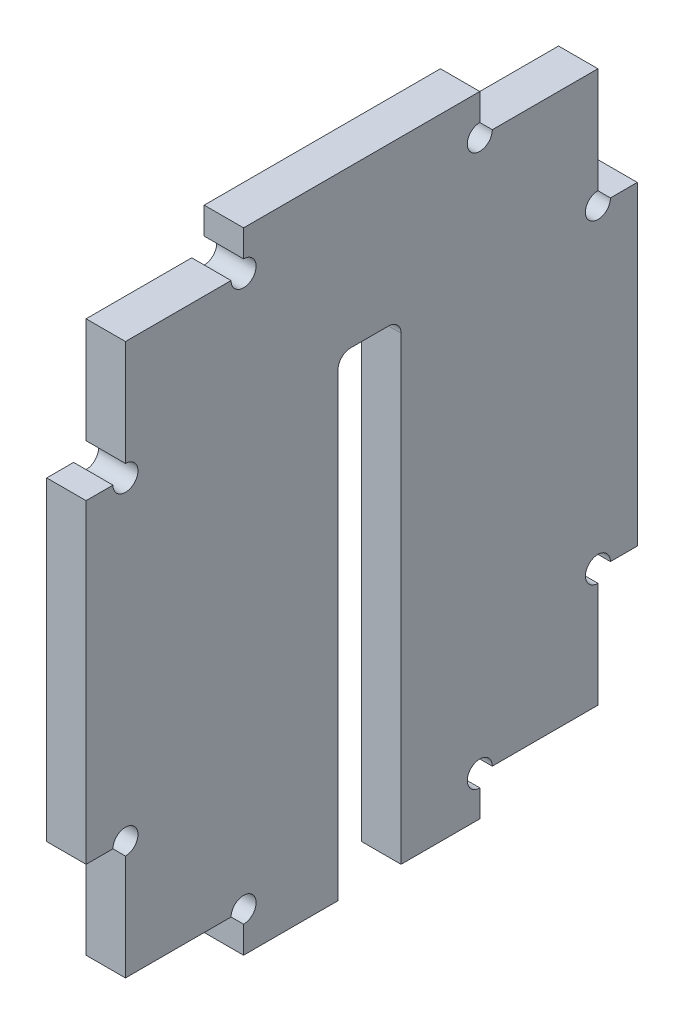
from build123d import *

# Parameters (mm, degrees)
SKETCH1_W                                = 70
SKETCH1_H                                = 80
BOSS_EXTRUDE1_DEPTH                      = 5
CUT_EXTRUDE1_START                       = -6
CUT_EXTRUDE1_DEPTH                       = 7
MIRROR1_START                            = -6
MIRROR1_AT_THE_SECOND_PLANE_COPY_1_DEPTH = 7
CUT_EXTRUDE2_DEPTH                       = 1
CUT_EXTRUDE2_DEPTH_BACK                  = 6
SKETCH5_R                                = 1.5875
CUT_EXTRUDE3_DEPTH                       = 6


with BuildPart() as part:
    # Sketch1 → Boss-Extrude1 (new body)
    with BuildSketch(Plane(origin=(0, 0, 0), x_dir=(0, 0, -1), z_dir=(1, 0, 0))):
        Rectangle(SKETCH1_W, SKETCH1_H)
    extrude(amount=BOSS_EXTRUDE1_DEPTH)

    # Sketch3 → Cut-Extrude1 (cut)
    with BuildSketch(Plane(origin=(5, 0, 0), x_dir=(0, 0, -1), z_dir=(1, 0, 0)).offset(CUT_EXTRUDE1_START)):
        Polygon((-35, 20), (-30, 20), (-30, 35), (-15, 35), (-15, 40), (-35, 40), align=None)
    cut_extrude1 = extrude(amount=CUT_EXTRUDE1_DEPTH, mode=Mode.SUBTRACT)

    # Mirror1: Cut-Extrude1 across plane
    add(cut_extrude1.mirror(Plane.XY), mode=Mode.SUBTRACT)

    # Mirror1 at the second plane: Cut-Extrude1 across plane
    add(cut_extrude1.mirror(Plane.ZX), mode=Mode.SUBTRACT)

    # Mirror1 at the second plane copy 1 sketc → Mirror1 at the second plane copy 1 (cut)
    with BuildSketch(Plane(origin=(5, 0, 0), x_dir=(0, 0, 1), z_dir=(1, 0, 0)).offset(MIRROR1_START)):
        Polygon((-35, 20), (-30, 20), (-30, 35), (-15, 35), (-15, 40), (-35, 40), align=None)
    extrude(amount=MIRROR1_AT_THE_SECOND_PLANE_COPY_1_DEPTH, mode=Mode.SUBTRACT)

    # Sketch4 → Cut-Extrude2 (cut, two sides)
    with BuildSketch(Plane(origin=(5, 0, 0), x_dir=(0, 0, -1), z_dir=(1, 0, 0))) as cut_extrude2_sk:
        with BuildLine():
            Line((-3, -40), (5, -40))
            Line((5, -40), (5, 18.4125))
            ThreePointArc((5, 18.4125), (4.535032015, 19.535032015), (3.4125, 20))
            Line((3.4125, 20), (-1.4125, 20))
            ThreePointArc((-1.4125, 20), (-2.535032015, 19.535032015), (-3, 18.4125))
            Line((-3, 18.4125), (-3, -40))
        make_face()
    extrude(amount=CUT_EXTRUDE2_DEPTH, mode=Mode.SUBTRACT)
    extrude(cut_extrude2_sk.sketch, amount=-CUT_EXTRUDE2_DEPTH_BACK, mode=Mode.SUBTRACT)

    # Sketch5 → Cut-Extrude3 (cut, through all)
    with BuildSketch(Plane(origin=(5, 0, 0), x_dir=(0, 0, -1), z_dir=(1, 0, 0))):
        with Locations((-15, 35)):
            Circle(SKETCH5_R)
        with Locations((15, 35)):
            Circle(SKETCH5_R)
        with Locations((30, 20)):
            Circle(SKETCH5_R)
        with Locations((30, -20)):
            Circle(SKETCH5_R)
        with Locations((15, -35)):
            Circle(SKETCH5_R)
        with Locations((-15, -35)):
            Circle(SKETCH5_R)
        with Locations((-30, -20)):
            Circle(SKETCH5_R)
        with Locations((-30, 20)):
            Circle(SKETCH5_R)
    extrude(amount=-CUT_EXTRUDE3_DEPTH, mode=Mode.SUBTRACT)


solid = part.part
